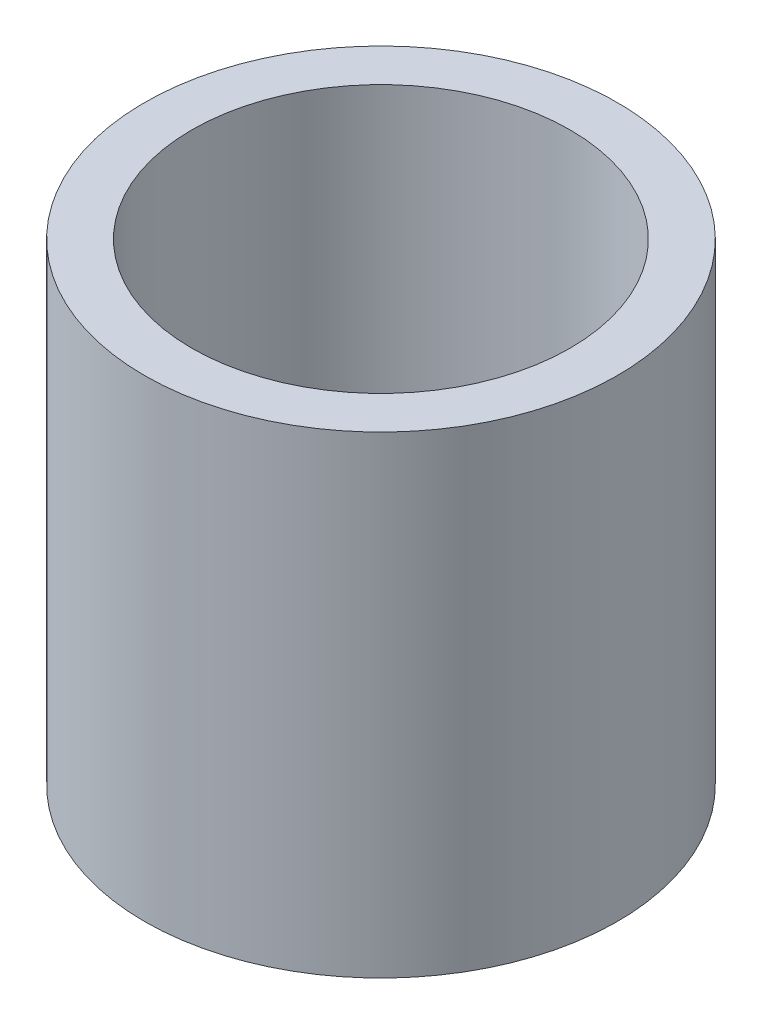
from build123d import *

# Parameters (mm, degrees)
SKETCH1_R           = 3.175
SKETCH1_R_2         = 2.54
BOSS_EXTRUDE1_DEPTH = 6.35


with BuildPart() as part:
    # Sketch1 → Boss-Extrude1 (new body)
    with BuildSketch(Plane(origin=(0, 0, 0), x_dir=(1, 0, 0), z_dir=(0, 1, 0))):
        Circle(SKETCH1_R)
        Circle(SKETCH1_R_2, mode=Mode.SUBTRACT)
    extrude(amount=BOSS_EXTRUDE1_DEPTH)


solid = part.part
